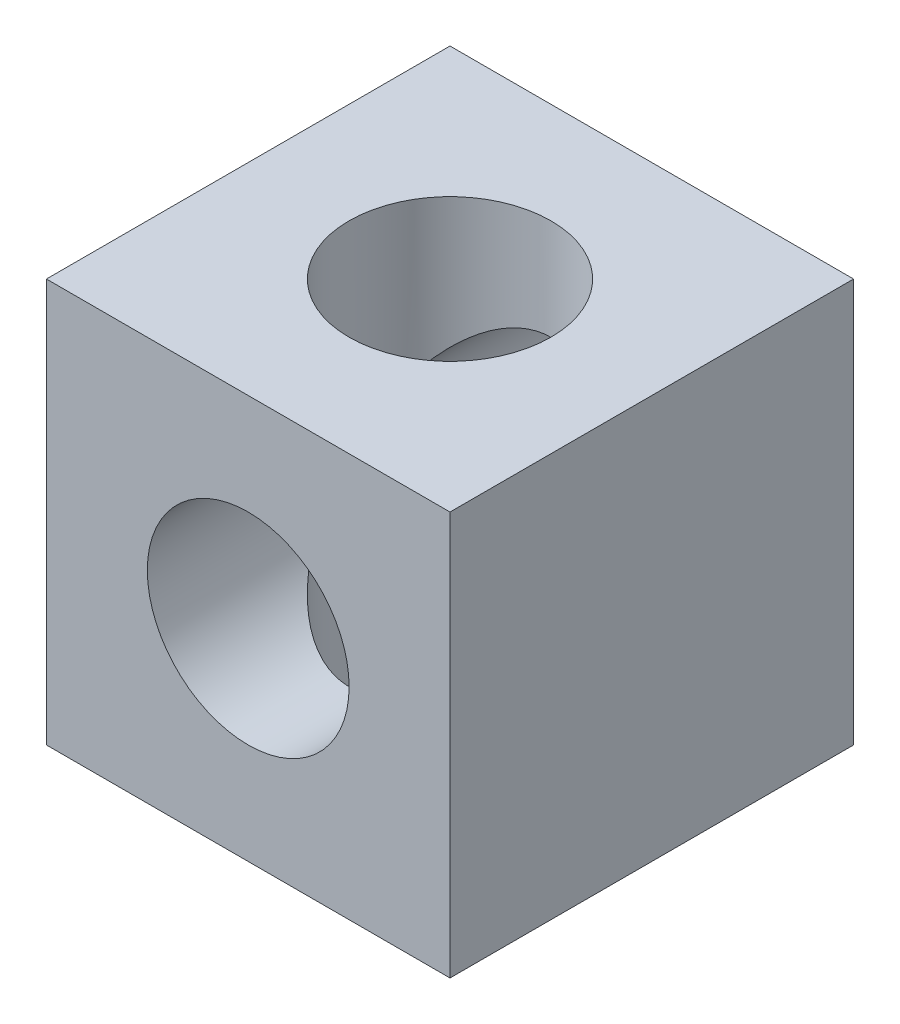
from build123d import *

# Parameters (mm, degrees)
SKETCH1_W           = 19
SKETCH1_H           = 19
BOSS_EXTRUDE1_DEPTH = 19
SKETCH2_R           = 4.75
CUT_EXTRUDE1_DEPTH  = 19
SKETCH3_R           = 4.75
CUT_EXTRUDE2_DEPTH  = 19


with BuildPart() as part:
    # Sketch1 → Boss-Extrude1 (new body)
    with BuildSketch(Plane(origin=(0, 0, 0), x_dir=(1, 0, 0), z_dir=(0, 1, 0))):
        with Locations((9.5, 9.5)):
            Rectangle(SKETCH1_W, SKETCH1_H)
    extrude(amount=BOSS_EXTRUDE1_DEPTH)

    # Sketch2 → Cut-Extrude1 (cut)
    with BuildSketch(Plane(origin=(0, 19, 0), x_dir=(1, 0, 0), z_dir=(0, 1, 0))):
        with Locations((9.5, 9.5)):
            Circle(SKETCH2_R)
    extrude(amount=-CUT_EXTRUDE1_DEPTH, mode=Mode.SUBTRACT)

    # Sketch3 → Cut-Extrude2 (cut)
    with BuildSketch(Plane.XY):
        with Locations((9.5, 9.5)):
            Circle(SKETCH3_R)
    extrude(amount=-CUT_EXTRUDE2_DEPTH, mode=Mode.SUBTRACT)


solid = part.part
